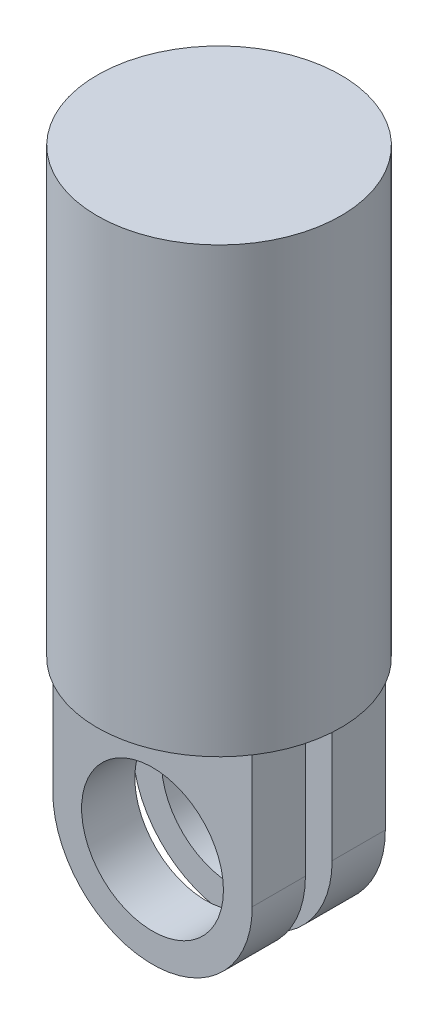
from build123d import *

# Parameters (mm, degrees)
SKETCH1_R           = 27.5
BOSS_EXTRUDE1_DEPTH = 100
BOSS_EXTRUDE3_START = -7
SKETCH6_R           = 16
BOSS_EXTRUDE3_DEPTH = 12


with BuildPart() as part:
    # Sketch1 → Boss-Extrude1 (new body)
    with BuildSketch(Plane(origin=(0, 0, 0), x_dir=(1, 0, 0), z_dir=(0, 1, 0))):
        Circle(SKETCH1_R)
    extrude(amount=BOSS_EXTRUDE1_DEPTH)

    # Sketch6 → Boss-Extrude3 (add)
    with BuildSketch(Plane.XY.offset(10.010953).offset(BOSS_EXTRUDE3_START)):
        with BuildLine():
            Line((22.5, 0), (-22.5, 0))
            Line((-22.5, 0), (-22.5, -30))
            ThreePointArc((-22.5, -30), (0, -52.508858033), (22.5, -30))
            Line((22.5, -30), (22.5, 0))
        make_face()
        with Locations((0, -30.00885629)):
            Circle(SKETCH6_R, mode=Mode.SUBTRACT)
    boss_extrude3 = extrude(amount=BOSS_EXTRUDE3_DEPTH)

    # Mirror1: Boss-Extrude3 across plane
    add(boss_extrude3.mirror(Plane.XY))


solid = part.part
